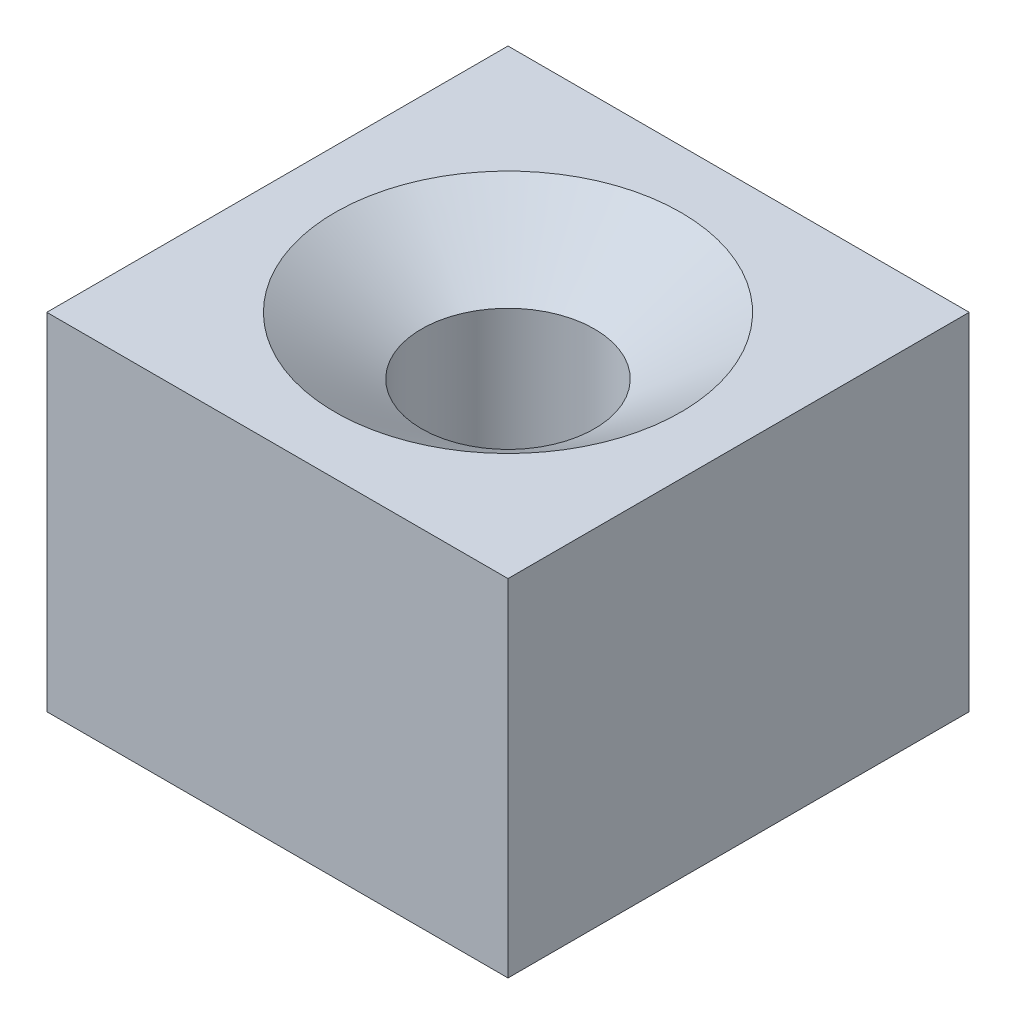
from build123d import *

# Parameters (mm, degrees)
SKETCH1_W           = 80
SKETCH1_H           = 80
BOSS_EXTRUDE1_DEPTH = 60


with BuildPart() as part:
    # Sketch1 → Boss-Extrude1 (new body)
    with BuildSketch(Plane(origin=(0, 0, 0), x_dir=(1, 0, 0), z_dir=(0, 1, 0))):
        Rectangle(SKETCH1_W, SKETCH1_H)
    extrude(amount=BOSS_EXTRUDE1_DEPTH)

    # Sketch2 → Cut-Revolve1 (revolve, cut)
    with BuildSketch(Plane.XY):
        Polygon((0, 60), (-30, 60), (-15, 50), (-15, 10), (0, 10), align=None)
    revolve(axis=Axis((0, 10, 0), (0, 1, 0)), mode=Mode.SUBTRACT)


solid = part.part
